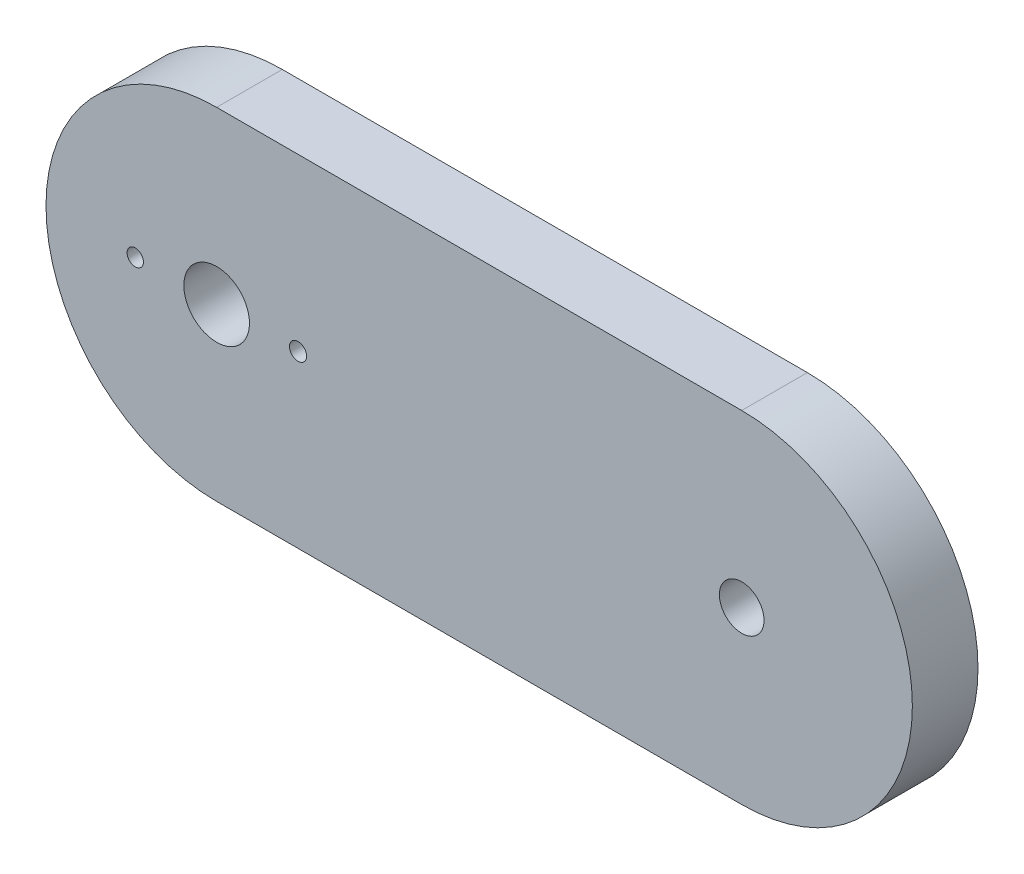
from build123d import *

# Parameters (mm, degrees)
SKETCH1_R           = 2.159
SKETCH1_R_2         = 3.175
BOSS_EXTRUDE1_DEPTH = 6.35
SKETCH2_R           = 7.759647624
SKETCH2_R_2         = 3.81
BOSS_EXTRUDE2_DEPTH = 1.27
SKETCH3_R           = 0.829532788
SKETCH3_R_2         = 0.792789718
CUT_EXTRUDE1_DEPTH  = 17.272


with BuildPart() as part:
    # Sketch1 → Boss-Extrude1 (new body)
    with BuildSketch(Plane.XY):
        with BuildLine():
            Line((-25.4, 16.51), (25.4, 16.51))
            ThreePointArc((25.4, 16.51), (41.91, 0), (25.4, -16.51))
            Line((25.4, -16.51), (-25.4, -16.51))
            ThreePointArc((-25.4, -16.51), (-41.91, 0), (-25.4, 16.51))
        make_face()
        with Locations((25.4, 0)):
            Circle(SKETCH1_R, mode=Mode.SUBTRACT)
        with Locations((-25.4, 0)):
            Circle(SKETCH1_R_2, mode=Mode.SUBTRACT)
    extrude(amount=BOSS_EXTRUDE1_DEPTH)

    # Sketch2 → Boss-Extrude2 (add)
    with BuildSketch(Plane.XY.offset(6.35)):
        with Locations((25.4, 0)):
            Circle(SKETCH2_R)
        with Locations((25.4, 0)):
            Circle(SKETCH2_R_2, mode=Mode.SUBTRACT)
    extrude(amount=-BOSS_EXTRUDE2_DEPTH)

    # Sketch3 → Cut-Extrude1 (cut)
    with BuildSketch(Plane(origin=(0, 0, 0), x_dir=(-1, 0, 0), z_dir=(0, 0, -1))):
        with Locations((17.526, 0)):
            Circle(SKETCH3_R)
        with Locations((33.274, 0)):
            Circle(SKETCH3_R_2)
    extrude(amount=-CUT_EXTRUDE1_DEPTH, mode=Mode.SUBTRACT)


solid = part.part
